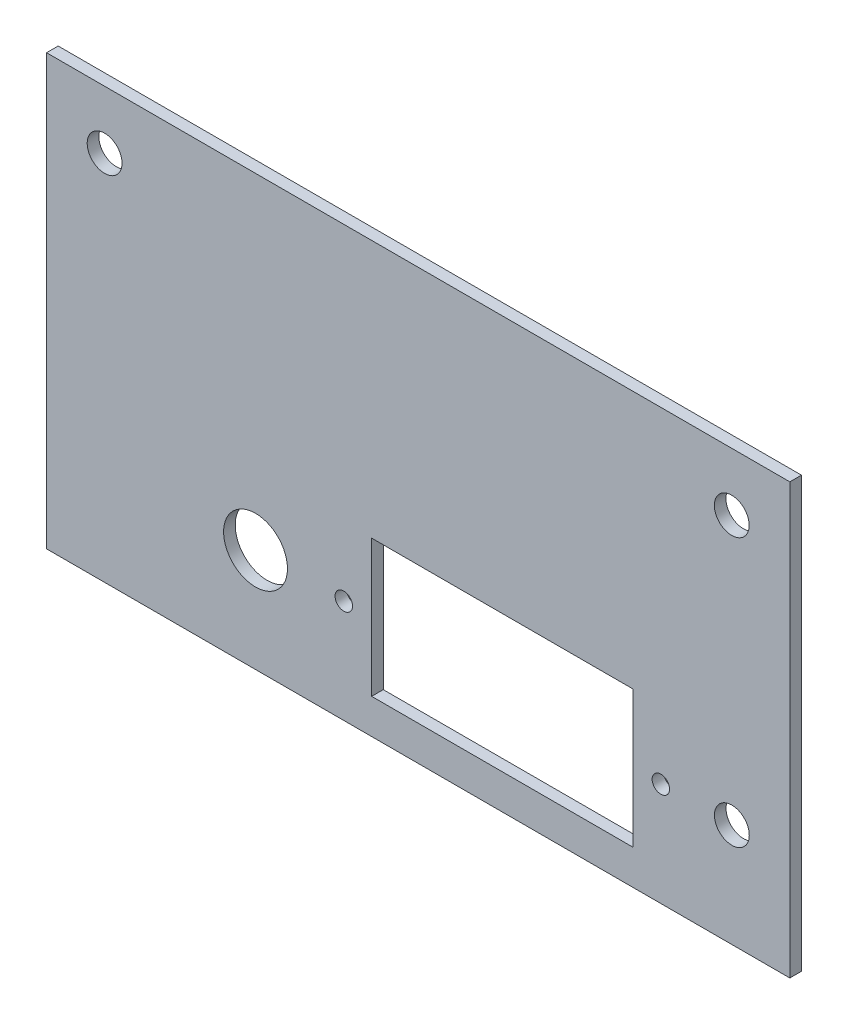
from build123d import *

# Parameters (mm, degrees)
CROQUIS1_W              = 64
CROQUIS1_H              = 37
CROQUIS1_R              = 1.5
CROQUIS1_R_2            = 0.75
CROQUIS1_R_3            = 2.750000001
CROQUIS1_R_4            = 1.500000001
CROQUIS1_W_2            = 22.5
CROQUIS1_H_2            = 11.8
SALIENTE_EXTRUIR1_DEPTH = 1


with BuildPart() as part:
    # Croquis1 → Saliente-Extruir1 (new body)
    with BuildSketch(Plane.XY):
        with Locations((8.682906488, 7.004854367)):
            Rectangle(CROQUIS1_W, CROQUIS1_H)
        with Locations((-18.317093512, 20.504854367)):
            Circle(CROQUIS1_R, mode=Mode.SUBTRACT)
        with Locations((35.682906488, 20.504854367)):
            Circle(CROQUIS1_R, mode=Mode.SUBTRACT)
        with Locations((29.576088128, -2.595145633)):
            Circle(CROQUIS1_R_2, mode=Mode.SUBTRACT)
        with Locations((2.276088128, -2.595145633)):
            Circle(CROQUIS1_R_2, mode=Mode.SUBTRACT)
        with Locations((-5.323911872, -2.595145633)):
            Circle(CROQUIS1_R_3, mode=Mode.SUBTRACT)
        with Locations((35.690737834, -2.595145633)):
            Circle(CROQUIS1_R_4, mode=Mode.SUBTRACT)
        with Locations((15.926088128, -2.595145633)):
            Rectangle(CROQUIS1_W_2, CROQUIS1_H_2, mode=Mode.SUBTRACT)
    extrude(amount=SALIENTE_EXTRUIR1_DEPTH)


solid = part.part
